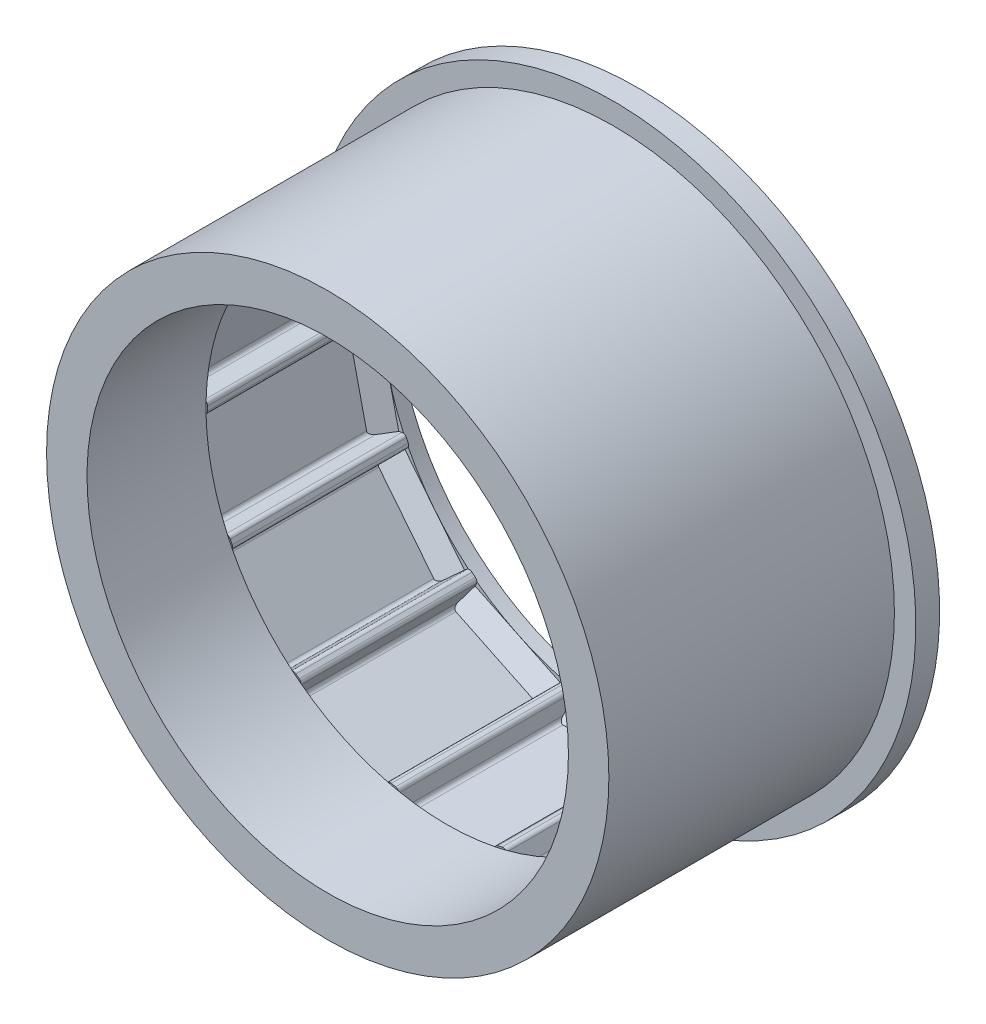
from build123d import *

# Parameters (mm, degrees)
SKETCH_1_R                       = 35.45
SKETCH_1_R_2                     = 30.15
EXTRUDE_1_DEPTH                  = 22.2
SKETCH_2_W                       = 12.1
SKETCH_2_H                       = 4.4
CUT_EXTRUDE_1_DEPTH              = 23.2
FILLET_1_R                       = 0.5
FILLET_2_R                       = 0.5
PATTERN_CIRCULAR_1_COUNT         = 14
FILLET_1_OF_PATTERN_CIRCULAR_1_R = 0.5
FILLET_2_OF_PATTERN_CIRCULAR_1_R = 0.5
SKETCH_3_R                       = 35.45
SKETCH_3_R_2                     = 30.35
EXTRUDE_2_DEPTH                  = 1.8
SKETCH_4_R                       = 35.45
SKETCH_4_R_2                     = 30.35
EXTRUDE_3_DEPTH                  = 15
EXTRUDE_4_DEPTH                  = 7
PATTERN_CIRCULAR_2_COUNT         = 14
SKETCH_7_R                       = 38.15
SKETCH_7_R_2                     = 35.45
EXTRUDE_6_DEPTH                  = 3


with BuildPart() as part:
    # ｽｹｯﾁ1 → ﾎﾞｽ - 押し出し1 (new body)
    with BuildSketch(Plane.XY):
        Circle(SKETCH_1_R)
        Circle(SKETCH_1_R_2, mode=Mode.SUBTRACT)
    extrude(amount=EXTRUDE_1_DEPTH)

    # ｽｹｯﾁ2 → ｶｯﾄ - 押し出し1 (cut, through all)
    with BuildSketch(Plane.XY.offset(22.2)):
        with Locations((0, 30.15)):
            Rectangle(SKETCH_2_W, SKETCH_2_H)
    cut_extrude_1 = extrude(amount=-CUT_EXTRUDE_1_DEPTH, mode=Mode.SUBTRACT)

    # ﾌｨﾚｯﾄ1
    fillet_1_edges = [part.edges().sort_by_distance(p)[0] for p in [
        (-6.05, 29.536756762, 11.1),
        (6.05, 29.536756762, 11.1),
    ]]
    fillet(fillet_1_edges, radius=FILLET_1_R)

    # ﾌｨﾚｯﾄ2
    fillet_2_edges = [part.edges().sort_by_distance(p)[0] for p in [
        (6.05, 32.35, 11.1),
        (-6.05, 32.35, 11.1),
    ]]
    fillet(fillet_2_edges, radius=FILLET_2_R)

    # 円形ﾊﾟﾀｰﾝ1: ｶｯﾄ - 押し出し1 ×14 about axis
    pattern_circular_1_axis = Axis((0, 0, 0), (0, 0, 1))
    for i in range(1, PATTERN_CIRCULAR_1_COUNT):
        add(cut_extrude_1.rotate(pattern_circular_1_axis, i * 360 / PATTERN_CIRCULAR_1_COUNT), mode=Mode.SUBTRACT)

    # ﾌｨﾚｯﾄ1 of 円形ﾊﾟﾀｰﾝ1
    fillet_1_of_pattern_circular_1_edges = [part.edges().sort_by_distance(p)[0] for p in [
        (-18.266380116, 23.986701679, 11.1),
        (-7.364656814, 29.236694923, 11.1),
        (-26.864879628, 13.685786152, 11.1),
        (-19.320653025, 23.14594709, 11.1),
        (-30.142460253, 0.674232832, 11.1),
        (-27.449956952, 12.470860569, 11.1),
        (-27.449956952, -12.470860569, 11.1),
        (-30.142460253, -0.674232832, 11.1),
        (-19.320653025, -23.14594709, 11.1),
        (-26.864879628, -13.685786152, 11.1),
        (-7.364656814, -29.236694923, 11.1),
        (-18.266380116, -23.986701679, 11.1),
        (6.05, -29.536756762, 11.1),
        (-6.05, -29.536756762, 11.1),
        (18.266380116, -23.986701679, 11.1),
        (7.364656814, -29.236694923, 11.1),
        (26.864879628, -13.685786152, 11.1),
        (19.320653025, -23.14594709, 11.1),
        (30.142460253, -0.674232832, 11.1),
        (27.449956952, -12.470860569, 11.1),
        (27.449956952, 12.470860569, 11.1),
        (30.142460253, 0.674232832, 11.1),
        (19.320653025, 23.14594709, 11.1),
        (26.864879628, 13.685786152, 11.1),
        (7.364656814, 29.236694923, 11.1),
        (18.266380116, 23.986701679, 11.1),
    ]]
    fillet(fillet_1_of_pattern_circular_1_edges, radius=FILLET_1_OF_PATTERN_CIRCULAR_1_R)

    # ﾌｨﾚｯﾄ2 of 円形ﾊﾟﾀｰﾝ1
    fillet_2_of_pattern_circular_1_edges = [part.edges().sort_by_distance(p)[0] for p in [
        (-8.58527731, 31.771339498, 11.1),
        (-19.487000611, 26.521346255, 11.1),
        (-21.520135157, 24.899975559, 11.1),
        (-29.064361759, 15.439814621, 11.1),
        (-30.192666309, 13.096866082, 11.1),
        (-32.88516961, 1.300238345, 11.1),
        (-32.88516961, -1.300238345, 11.1),
        (-30.192666309, -13.096866082, 11.1),
        (-29.064361759, -15.439814621, 11.1),
        (-21.520135157, -24.899975559, 11.1),
        (-19.487000611, -26.521346255, 11.1),
        (-8.58527731, -31.771339498, 11.1),
        (-6.05, -32.35, 11.1),
        (6.05, -32.35, 11.1),
        (8.58527731, -31.771339498, 11.1),
        (19.487000611, -26.521346255, 11.1),
        (21.520135157, -24.899975559, 11.1),
        (29.064361759, -15.439814621, 11.1),
        (30.192666309, -13.096866082, 11.1),
        (32.88516961, -1.300238345, 11.1),
        (32.88516961, 1.300238345, 11.1),
        (30.192666309, 13.096866082, 11.1),
        (29.064361759, 15.439814621, 11.1),
        (21.520135157, 24.899975559, 11.1),
        (19.487000611, 26.521346255, 11.1),
        (8.58527731, 31.771339498, 11.1),
    ]]
    fillet(fillet_2_of_pattern_circular_1_edges, radius=FILLET_2_OF_PATTERN_CIRCULAR_1_R)

    # ｽｹｯﾁ3 → ﾎﾞｽ - 押し出し2 (add)
    with BuildSketch(Plane(origin=(0, 0, 0), x_dir=(-1, 0, 0), z_dir=(0, 0, -1))):
        Circle(SKETCH_3_R)
        Circle(SKETCH_3_R_2, mode=Mode.SUBTRACT)
    extrude(amount=EXTRUDE_2_DEPTH)

    # ｽｹｯﾁ4 → ﾎﾞｽ - 押し出し3 (add)
    with BuildSketch(Plane.XY.offset(22.2)):
        Circle(SKETCH_4_R)
        Circle(SKETCH_4_R_2, mode=Mode.SUBTRACT)
    extrude(amount=EXTRUDE_3_DEPTH)

    # ｽｹｯﾁ6 → ﾎﾞｽ - 押し出し4 (add, symmetric)
    with BuildSketch(Plane(origin=(0, 0, 0), x_dir=(0, 0, -1), z_dir=(1, 0, 0))):
        Polygon((0, -30.35), (0, -33.35), (-3, -33.35), align=None)
    extrude_4 = extrude(amount=EXTRUDE_4_DEPTH, both=True)

    # 円形ﾊﾟﾀｰﾝ2: ﾎﾞｽ - 押し出し4 ×14 about axis
    pattern_circular_2_axis = Axis((0, 0, 0), (0, 0, 1))
    for i in range(1, PATTERN_CIRCULAR_2_COUNT):
        add(extrude_4.rotate(pattern_circular_2_axis, i * 360 / PATTERN_CIRCULAR_2_COUNT))

    # ｽｹｯﾁ7 → ﾎﾞｽ - 押し出し6 (add)
    with BuildSketch(Plane(origin=(0, 0, -1.8), x_dir=(-1, 0, 0), z_dir=(0, 0, -1))):
        Circle(SKETCH_7_R)
        Circle(SKETCH_7_R_2, mode=Mode.SUBTRACT)
    extrude(amount=-EXTRUDE_6_DEPTH)


solid = part.part
